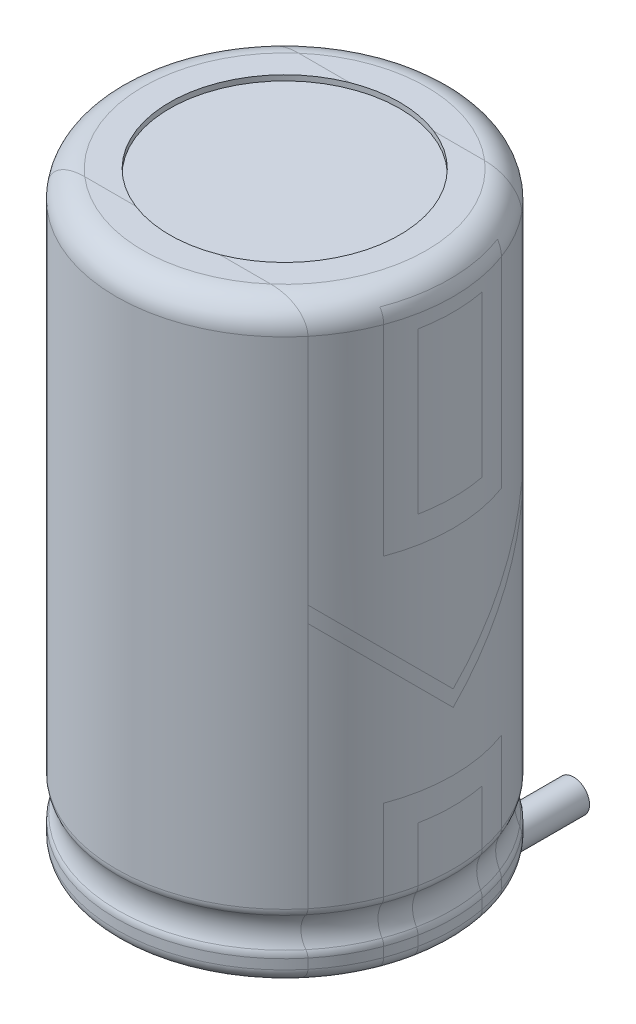
from build123d import *

# Parameters (mm, degrees)
SKETCH4_R = 0.3


with BuildPart() as part:
    # Sketch1 → Revolve1 (revolve)
    with BuildSketch(Plane.XY):
        with BuildLine():
            Line((0, 10.9), (2.15, 10.9))
            Line((2.15, 10.9), (2.15, 11))
            Line((2.15, 11), (2.65, 11))
            ThreePointArc((2.65, 11), (3.003553391, 10.853553391), (3.15, 10.5))
            Line((3.15, 10.5), (3.15, 1.231662479))
            ThreePointArc((3.15, 1.231662479), (3.142535625, 1.171028573), (3.120588235, 1.11401542))
            ThreePointArc((3.120588235, 1.11401542), (3.05, 0.831662479), (3.120588235, 0.549309538))
            ThreePointArc((3.120588235, 0.549309538), (3.142535625, 0.492296385), (3.15, 0.431662479))
            Line((3.15, 0.431662479), (3.15, 0.25))
            ThreePointArc((3.15, 0.25), (3.076776695, 0.073223305), (2.9, 0))
            Line((2.9, 0), (0, 0))
            Line((0, 0), (0, 10.9))
        make_face()
    revolve(axis=Axis((0, 0, 0), (0, 1, 0)))

    # Sweep1: sweep along a path in Sketch5
    with BuildLine(Plane(origin=(-1.25, 0, 0), x_dir=(0, 0, -1), z_dir=(1, 0, 0))) as sweep1_path:
        Line((0, 0), (0, -0.1))
        ThreePointArc((0, -0.1), (0.146446609, -0.453553391), (0.5, -0.6))
        Line((0.5, -0.6), (4.15, -0.6))
    # Sketch4 → Sweep1 (sweep)
    with BuildSketch(Plane.XZ):
        with Locations((-1.25, 0)):
            Circle(SKETCH4_R)
    sweep1 = sweep(path=sweep1_path.line)

    # Mirror1: Sweep1 across plane
    add(sweep1.mirror(Plane(origin=(0, 0, 0), x_dir=(0, 0, 1), z_dir=(1, 0, 0))))


solid = part.part
